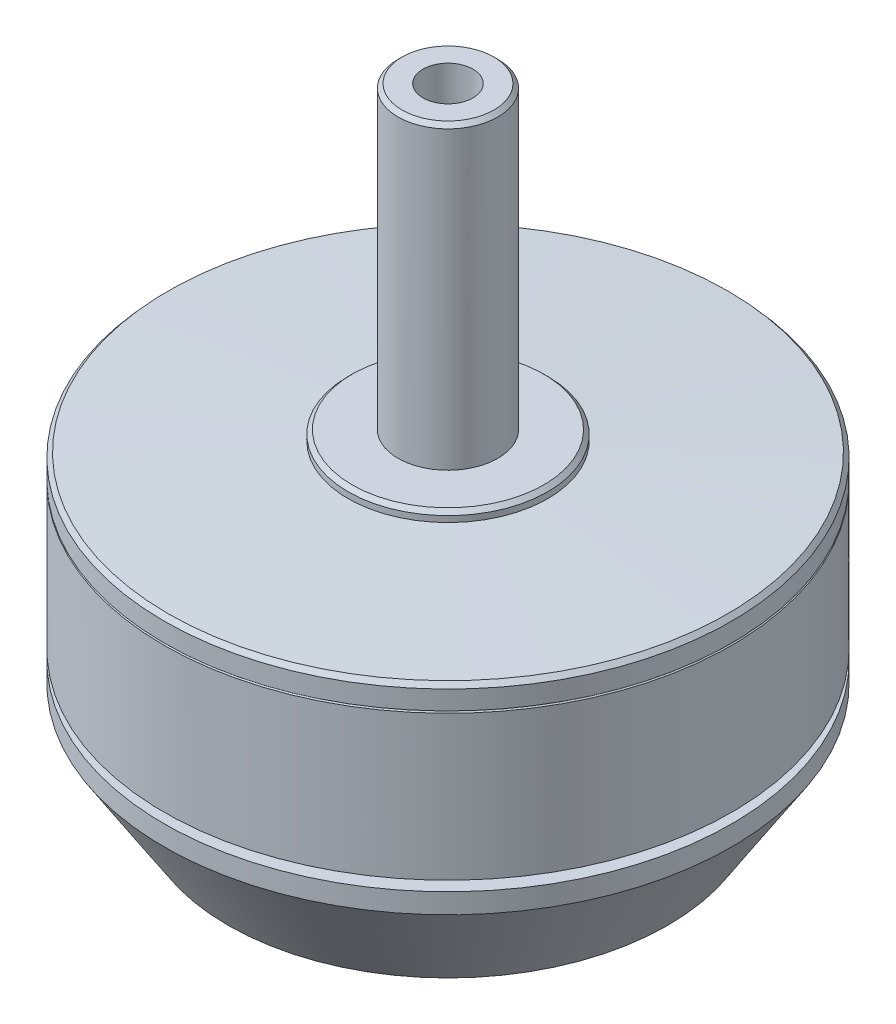
from build123d import *

# Parameters (mm, degrees)
CHAMFER_1_SIZE         = 0.2
CHAMFER_1_EDGE_2_SIZE  = 0.2
CHAMFER_1_EDGE_3_SIZE2 = 0.211806366
CHAMFER_1_EDGE_3_SIZE  = 0.2
CHAMFER_1_EDGE_4_SIZE  = 0.2
SKETCH_4_R             = 0.05


with BuildPart() as part:
    # 草图1 → 旋转1 (revolve)
    with BuildSketch(Plane.XY):
        Polygon((0, 0.750762333), (0, 19.059798334), (1.25, 19.059798334), (1.25, 31), (2.5, 31), (2.5, 16), (5, 16), (5, 15.5), (14.2, 15), (14.2, 6.5), (11, 6.5), (11, 6), (14.2, 6), (14.2, 5), (11, 0), (6, 0), (6, 0.750762333), align=None)
    revolve(axis=Axis((0, 0.750762333, 0), (0, 1, 0)))

    # 倒角1
    chamfer_1_edges = [part.edges().sort_by_distance(p)[0] for p in [
        (-2.5, 31, 0),
    ]]
    chamfer(chamfer_1_edges, length=CHAMFER_1_SIZE)

    # 倒角1 edge 2
    chamfer_1_edge_2_edges = [part.edges().sort_by_distance(p)[0] for p in [
        (-5, 16, 0),
    ]]
    chamfer(chamfer_1_edge_2_edges, length=CHAMFER_1_EDGE_2_SIZE)

    # 倒角1 edge 3
    chamfer_1_edge_3_edges = [part.edges().sort_by_distance(p)[0] for p in [
        (-14.2, 15, 0),
    ]]
    chamfer(chamfer_1_edge_3_edges, length=CHAMFER_1_EDGE_3_SIZE, length2=CHAMFER_1_EDGE_3_SIZE2)

    # 倒角1 edge 4
    chamfer_1_edge_4_edges = [part.edges().sort_by_distance(p)[0] for p in [
        (-6, 0, 0),
    ]]
    chamfer(chamfer_1_edge_4_edges, length=CHAMFER_1_EDGE_4_SIZE)

    # 草图4 → 切除-旋转4 (revolve, cut)
    with BuildSketch(Plane.XY):
        with Locations((14.193753357, 13.788193634)):
            Circle(SKETCH_4_R)
    revolve(axis=Axis((0, 32.55, 0), (0, -1, 0)), mode=Mode.SUBTRACT)


solid = part.part
